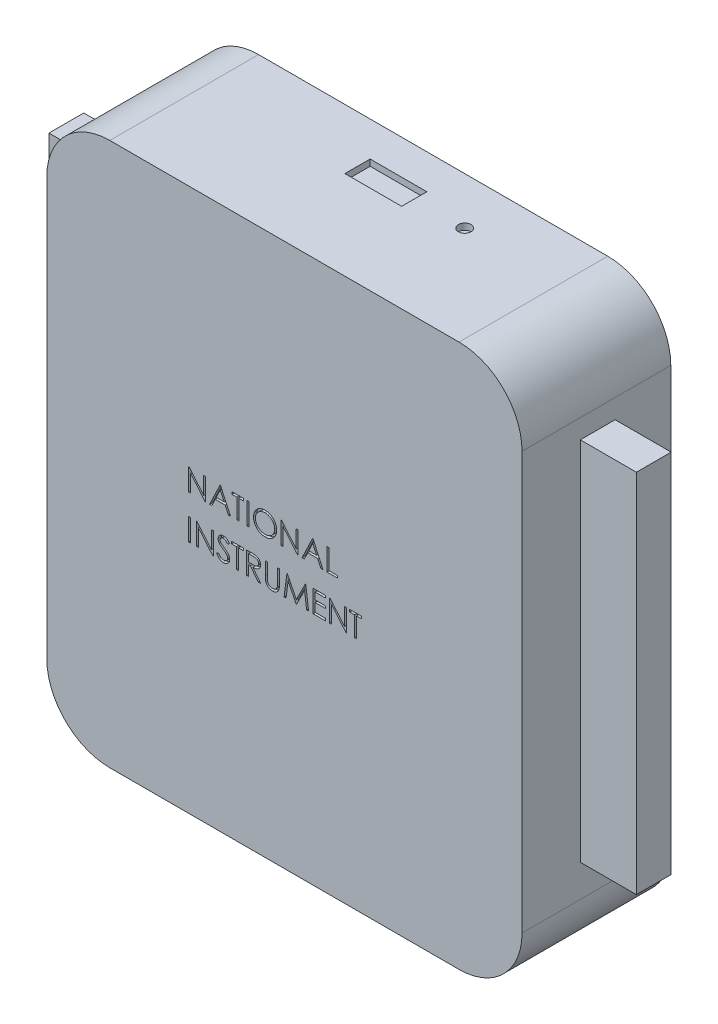
from build123d import *

# Parameters (mm, degrees)
SKETCH1_W                = 75.4
SKETCH1_H                = 86.2
BOSS_EXTRUDE1_DEPTH      = 23.6
SKETCH2_W                = 5.523445924
SKETCH2_H                = 58.042494048
BOSS_EXTRUDE2_DEPTH      = 8.9
BOSS_EXTRUDE2_DEPTH_BACK = 84.3
SKETCH3_W                = 0.314102564
SKETCH3_H                = 3.5
CUT_EXTRUDE1_DEPTH       = 0.5
FILLET1_R                = 10
SKETCH5_R                = 1
SKETCH5_W                = 9
SKETCH5_H                = 4
CUT_EXTRUDE2_DEPTH       = 1


with BuildPart() as part:
    # Sketch1 → Boss-Extrude1 (new body)
    with BuildSketch(Plane.XY):
        with Locations((37.7, 43.1)):
            Rectangle(SKETCH1_W, SKETCH1_H)
    extrude(amount=BOSS_EXTRUDE1_DEPTH)

    # Sketch2 → Boss-Extrude2 (add, two sides)
    with BuildSketch(Plane.ZY) as boss_extrude2_sk:
        with Locations((11.597208394, 44.124044053)):
            Rectangle(SKETCH2_W, SKETCH2_H)
    extrude(amount=BOSS_EXTRUDE2_DEPTH)
    extrude(boss_extrude2_sk.sketch, amount=-BOSS_EXTRUDE2_DEPTH_BACK)

    # Sketch3 → Cut-Extrude1 (cut)
    with BuildSketch(Plane.XY.offset(23.6)):
        Polygon((22.517751212, 44.125723562), (22.517751212, 47.625723562), (22.583656661, 47.625723562), (24.89595634, 44.87101603), (24.89595634, 47.625723562), (25.210058904, 47.625723562), (25.210058904, 44.125723562), (25.138544481, 44.125723562), (22.831853776, 46.874120998), (22.831853776, 44.125723562), align=None)
        Polygon((27.543392238, 47.625723562), (29.158776853, 44.125723562), (28.817330539, 44.125723562), (28.299902654, 45.247518434), (26.713264033, 45.247518434), (26.18111259, 44.125723562), (25.838264033, 44.125723562), (27.498520443, 47.625723562), align=None)
        Polygon((27.517450731, 46.943532055), (26.883636629, 45.606492792), (28.134437911, 45.606492792), align=None, mode=Mode.SUBTRACT)
        Polygon((29.383135827, 47.266749203), (29.383135827, 47.625723562), (31.222879417, 47.625723562), (31.222879417, 47.266749203), (30.460058904, 47.266749203), (30.460058904, 44.125723562), (30.14595634, 44.125723562), (30.14595634, 47.266749203), align=None)
        with Locations((31.918392238, 45.875723562)):
            Rectangle(SKETCH3_W, SKETCH3_H)
        with BuildLine():
            add(Edge.make_bspline(
                [(34.61069993, 47.715467151), (34.675508036, 47.713825672), (34.802796503, 47.710601671), (34.989871401, 47.685922568), (35.168466496, 47.643227178), (35.340036635, 47.586364195), (35.502529611, 47.51050981), (35.657168504, 47.418824661), (35.803585378, 47.310348203), (35.939806759, 47.185918976), (36.064463709, 47.050535522), (36.174289596, 46.906057612), (36.266331889, 46.75335881), (36.341917677, 46.592897979), (36.401216286, 46.425038011), (36.44213533, 46.248884008), (36.46827348, 46.065577318), (36.471329258, 45.940550453), (36.472879417, 45.877125805)],
                knots=[0, 0, 0, 0, 0.000194393, 0.000381804, 0.00056479, 0.000744601, 0.000923091, 0.001101652, 0.001283106, 0.001468738, 0.001654324, 0.001834514, 0.002012231, 0.002188181, 0.002365797, 0.002545211, 0.002729936, 0.002920126, 0.002920126, 0.002920126, 0.002920126], degree=3))
            add(Edge.make_bspline(
                [(36.472879417, 45.877125805), (36.471329485, 45.814168359), (36.468274388, 45.690071939), (36.442105611, 45.507928494), (36.401064611, 45.332837798), (36.342468344, 45.165092145), (36.267242866, 45.004514581), (36.174587695, 44.851527627), (36.065446484, 44.706081129), (35.941239633, 44.569768464), (35.805838591, 44.444770993), (35.660608324, 44.335852117), (35.508815004, 44.242127993), (35.348505296, 44.167344319), (35.181805259, 44.107572398), (35.007222936, 44.066819768), (34.825576382, 44.040532725), (34.701705378, 44.037514209), (34.638744802, 44.035979972)],
                knots=[0, 0, 0, 0, 0.000188789, 0.000372126, 0.000550857, 0.00072758, 0.000904164, 0.001081881, 0.001263191, 0.001448823, 0.00163441, 0.001815159, 0.001992641, 0.002168591, 0.002344885, 0.002522934, 0.002705576, 0.002894365, 0.002894365, 0.002894365, 0.002894365], degree=3))
            add(Edge.make_bspline(
                [(34.638744802, 44.035979972), (34.575320483, 44.037529359), (34.450294267, 44.040583613), (34.266757232, 44.066765018), (34.090479488, 44.107706321), (33.921965136, 44.166215758), (33.761120207, 44.241832988), (33.607630124, 44.334037367), (33.462110977, 44.443444509), (33.32576923, 44.567611083), (33.201020032, 44.702782635), (33.092260657, 44.84761689), (33.000035543, 44.999272347), (32.924672211, 45.158169871), (32.865007751, 45.323541314), (32.824302933, 45.496489791), (32.797966981, 45.676029297), (32.794932135, 45.798272195), (32.793392238, 45.860298882)],
                knots=[0, 0, 0, 0, 0.00019019, 0.000374915, 0.000555011, 0.000732396, 0.00090898, 0.001087298, 0.001268608, 0.00145424, 0.001639827, 0.001819595, 0.001996712, 0.002171394, 0.002346367, 0.002523053, 0.002703612, 0.002889599, 0.002889599, 0.002889599, 0.002889599], degree=3))
            add(Edge.make_bspline(
                [(32.793392238, 45.860298882), (32.793926873, 45.901931551), (32.7949894, 45.984671675), (32.807781092, 46.107538275), (32.826342793, 46.228428933), (32.852944706, 46.346999881), (32.887736373, 46.462960865), (32.9287884, 46.577111628), (32.978928246, 46.688295352), (33.035608894, 46.797038744), (33.098870702, 46.90164665), (33.168746451, 47.000526233), (33.24278182, 47.09450723), (33.323945213, 47.181154233), (33.409561658, 47.26298789), (33.501020036, 47.338750607), (33.597762281, 47.409125558), (33.700204661, 47.472545899), (33.805822935, 47.529905033), (33.914699713, 47.579126884), (34.025356285, 47.621372946), (34.138310933, 47.655613771), (34.253263705, 47.682645807), (34.370465489, 47.701053161), (34.489822916, 47.713877479), (34.570234235, 47.714934981), (34.61069993, 47.715467151)],
                knots=[0, 0, 0, 0, 0.000124849, 0.000248123, 0.000370193, 0.00049164, 0.000612319, 0.000733199, 0.000855287, 0.000977905, 0.001100913, 0.001221706, 0.001340948, 0.001459521, 0.001577551, 0.001696047, 0.001815534, 0.001936153, 0.002057243, 0.002175846, 0.002294342, 0.002412335, 0.002529682, 0.00264829, 0.002768075, 0.00288942, 0.00288942, 0.00288942, 0.00288942], degree=3))
        make_face()
        with BuildLine():
            add(Edge.make_bspline(
                [(34.62612461, 47.356492792), (34.592909976, 47.356087902), (34.526798243, 47.355281993), (34.428513707, 47.344666277), (34.331521773, 47.329536388), (34.235802411, 47.307954867), (34.141756121, 47.278550814), (34.04850628, 47.244709906), (33.956903226, 47.203488816), (33.867249369, 47.156916111), (33.780334293, 47.10536719), (33.698321592, 47.048395423), (33.620998948, 46.987336869), (33.548555681, 46.922049032), (33.481204509, 46.85219943), (33.417619808, 46.778846994), (33.360350226, 46.699895103), (33.307864649, 46.617484696), (33.260896809, 46.531723115), (33.219131454, 46.443513253), (33.184967445, 46.352135566), (33.157105069, 46.258581408), (33.134005258, 46.162998948), (33.119371334, 46.0646631), (33.108638975, 45.964067988), (33.107879129, 45.896086134), (33.107494802, 45.861701126)],
                knots=[0, 0, 0, 0, 9.9599e-05, 0.000198245, 0.000296222, 0.00039402, 0.00049227, 0.000591646, 0.000691452, 0.000793368, 0.000894612, 0.000994383, 0.001092713, 0.00119001, 0.001286696, 0.001383657, 0.001480979, 0.001579008, 0.001676595, 0.001774142, 0.001871547, 0.001968922, 0.002066879, 0.00216624, 0.00226698, 0.002370083, 0.002370083, 0.002370083, 0.002370083], degree=3))
            add(Edge.make_bspline(
                [(33.107494802, 45.861701126), (33.108769664, 45.811138905), (33.111277712, 45.711667375), (33.133235282, 45.565899231), (33.167057256, 45.425810945), (33.216914623, 45.292169035), (33.279265237, 45.163824752), (33.356292128, 45.041916648), (33.447551213, 44.926411773), (33.55121474, 44.818116504), (33.664537446, 44.7192707), (33.784870176, 44.632507291), (33.910923784, 44.559097042), (34.043026986, 44.499291969), (34.180474526, 44.451902231), (34.324152077, 44.4194236), (34.473102536, 44.398048145), (34.574633191, 44.395995389), (34.62612461, 44.394954331)],
                knots=[0, 0, 0, 0, 0.000151605, 0.000298253, 0.000441263, 0.000583229, 0.000725274, 0.000868635, 0.001014928, 0.001166177, 0.001317744, 0.00146543, 0.001610576, 0.001754594, 0.001899821, 0.002045914, 0.002195936, 0.002350312, 0.002350312, 0.002350312, 0.002350312], degree=3))
            add(Edge.make_bspline(
                [(34.62612461, 44.394954331), (34.660734111, 44.395429835), (34.729375148, 44.396372903), (34.83147067, 44.40587158), (34.931726882, 44.42110345), (35.030003161, 44.443034105), (35.126187973, 44.470481312), (35.220682776, 44.50308904), (35.312481066, 44.543770243), (35.402740904, 44.588718195), (35.489137146, 44.639958352), (35.571612678, 44.694996502), (35.648088658, 44.755965123), (35.720477729, 44.820282935), (35.788105418, 44.889246783), (35.850514403, 44.962767005), (35.907494535, 45.041307662), (35.959960181, 45.123593068), (36.006763444, 45.209589321), (36.047542543, 45.298118999), (36.082138659, 45.388964108), (36.110067164, 45.482255679), (36.131952625, 45.577816528), (36.147032545, 45.675774606), (36.157580984, 45.775933949), (36.158376061, 45.843677805), (36.158776853, 45.877826927)],
                knots=[0, 0, 0, 0, 0.000103804, 0.000205874, 0.000307314, 0.000407849, 0.000507719, 0.000607281, 0.000707445, 0.000808723, 0.000909609, 0.001008589, 0.001105934, 0.001202762, 0.001298946, 0.001395452, 0.001491794, 0.001589823, 0.001688026, 0.001785277, 0.001882027, 0.001979402, 0.0020772, 0.002175869, 0.002276609, 0.002379011, 0.002379011, 0.002379011, 0.002379011], degree=3))
            add(Edge.make_bspline(
                [(36.158776853, 45.877826927), (36.15837574, 45.911742431), (36.157580059, 45.979020082), (36.147037584, 46.0784809), (36.131936694, 46.175734111), (36.110173986, 46.270397914), (36.082123832, 46.362496439), (36.047536502, 46.451943187), (36.006751202, 46.539071382), (35.959942978, 46.623665679), (35.907327154, 46.704840417), (35.849832911, 46.78244283), (35.786467563, 46.855015571), (35.719041538, 46.924350265), (35.645870653, 46.988968155), (35.567286358, 47.048890675), (35.484242681, 47.10556395), (35.396315445, 47.156689511), (35.305571492, 47.203903744), (35.212457534, 47.244354747), (35.118028434, 47.278726867), (35.022524322, 47.308043832), (34.925141343, 47.329451862), (34.826537514, 47.344679912), (34.726849256, 47.355278298), (34.659806036, 47.356086676), (34.62612461, 47.356492792)],
                knots=[0, 0, 0, 0, 0.000101701, 0.000201743, 0.00029972, 0.000396835, 0.000492868, 0.000588308, 0.000684288, 0.000781261, 0.000878109, 0.000974304, 0.001070733, 0.001166917, 0.001264269, 0.001363274, 0.001463228, 0.001565678, 0.001668217, 0.001769947, 0.001869982, 0.001969573, 0.002069423, 0.002168785, 0.002268827, 0.002369827, 0.002369827, 0.002369827, 0.002369827], degree=3))
        make_face(mode=Mode.SUBTRACT)
        Polygon((37.190828135, 44.125723562), (37.190828135, 47.625723562), (37.256733584, 47.625723562), (39.569033263, 44.87101603), (39.569033263, 47.625723562), (39.883135827, 47.625723562), (39.883135827, 44.125723562), (39.811621404, 44.125723562), (37.504930699, 46.874120998), (37.504930699, 44.125723562), align=None)
        Polygon((42.216469161, 47.625723562), (43.831853776, 44.125723562), (43.490407462, 44.125723562), (42.972979577, 45.247518434), (41.386340956, 45.247518434), (40.854189513, 44.125723562), (40.511340956, 44.125723562), (42.171597366, 47.625723562), align=None)
        Polygon((42.190527654, 46.943532055), (41.556713552, 45.606492792), (42.807514834, 45.606492792), align=None, mode=Mode.SUBTRACT)
        Polygon((44.460058904, 47.625723562), (44.774161469, 47.625723562), (44.774161469, 44.484697921), (46.120315315, 44.484697921), (46.120315315, 44.125723562), (44.460058904, 44.125723562), align=None)
        with Locations((22.674802494, 39.042390228)):
            Rectangle(SKETCH3_W, SKETCH3_H)
        Polygon((23.729289674, 37.292390228), (23.729289674, 40.792390228), (23.795195122, 40.792390228), (26.107494802, 38.037682696), (26.107494802, 40.792390228), (26.421597366, 40.792390228), (26.421597366, 37.292390228), (26.350082943, 37.292390228), (24.043392238, 40.040787664), (24.043392238, 37.292390228), align=None)
        with BuildLine():
            Line((26.960058904, 37.967570517), (27.255932302, 38.144954331))
            add(Edge.make_bspline(
                [(27.255932302, 38.144954331), (27.283450539, 38.098889946), (27.33617442, 38.010632362), (27.424125779, 37.891374322), (27.51525869, 37.790012165), (27.610248024, 37.707135557), (27.708513972, 37.641886671), (27.810698025, 37.595684439), (27.916455836, 37.566868464), (27.988429658, 37.563368377), (28.024361789, 37.561620998)],
                knots=[0, 0, 0, 0, 0.000160901, 0.00030828, 0.000443778, 0.00056903, 0.000685513, 0.000796284, 0.00090427, 0.001011928, 0.001011928, 0.001011928, 0.001011928], degree=3))
            add(Edge.make_bspline(
                [(28.024361789, 37.561620998), (28.05504865, 37.56247567), (28.115885423, 37.56417006), (28.205447666, 37.580450862), (28.292429468, 37.605462991), (28.375038106, 37.641283923), (28.45213372, 37.684622409), (28.519740415, 37.736968586), (28.578186529, 37.795574792), (28.625995643, 37.860957446), (28.662675678, 37.931274595), (28.690867747, 38.003450546), (28.706512821, 38.078619115), (28.708869574, 38.129229578), (28.710058904, 38.154770036)],
                knots=[0, 0, 0, 0, 9.1978e-05, 0.000182347, 0.000272202, 0.000362975, 0.000451852, 0.000536835, 0.000618639, 0.000699414, 0.000778765, 0.000855983, 0.0009312, 0.001007828, 0.001007828, 0.001007828, 0.001007828], degree=3))
            add(Edge.make_bspline(
                [(28.710058904, 38.154770036), (28.708584594, 38.183910886), (28.705587535, 38.243149975), (28.680256055, 38.330549628), (28.640406809, 38.417042198), (28.603644165, 38.470543463), (28.584558103, 38.498319716)],
                knots=[0, 0, 0, 0, 8.7281e-05, 0.000177429, 0.000270909, 0.000371844, 0.000371844, 0.000371844, 0.000371844], degree=3))
            add(Edge.make_bspline(
                [(28.584558103, 38.498319716), (28.568887489, 38.518366539), (28.535988995, 38.560452338), (28.479431482, 38.623097573), (28.413065368, 38.687715992), (28.339161813, 38.756775049), (28.255028724, 38.827062846), (28.16330121, 38.901931124), (28.061637351, 38.978532701), (27.990337854, 39.029905266), (27.953548488, 39.056412664)],
                knots=[0, 0, 0, 0, 7.6319e-05, 0.000160223, 0.000252933, 0.000354147, 0.000463581, 0.000581729, 0.000709336, 0.000845369, 0.000845369, 0.000845369, 0.000845369], degree=3))
            add(Edge.make_bspline(
                [(27.953548488, 39.056412664), (27.916724492, 39.082641252), (27.846319815, 39.132788314), (27.747861233, 39.207212598), (27.65981677, 39.275256468), (27.582577753, 39.33756048), (27.516178156, 39.394133085), (27.460094745, 39.444431024), (27.415756188, 39.489814585), (27.391100607, 39.519255926), (27.38003086, 39.532474363)],
                knots=[0, 0, 0, 0, 0.000135623, 0.000259301, 0.000370234, 0.000469439, 0.00055697, 0.000631911, 0.000695377, 0.00074709, 0.00074709, 0.00074709, 0.00074709], degree=3))
            add(Edge.make_bspline(
                [(27.38003086, 39.532474363), (27.364558314, 39.5530754), (27.334129478, 39.593590104), (27.293963472, 39.656914961), (27.259824309, 39.721738227), (27.233061977, 39.788234091), (27.210525758, 39.85546902), (27.195367828, 39.924320266), (27.185876431, 39.994478884), (27.184904444, 40.041692385), (27.184417879, 40.065326927)],
                knots=[0, 0, 0, 0, 7.727e-05, 0.000151962, 0.000224716, 0.000296717, 0.00036678, 0.0004372, 0.000507902, 0.000578771, 0.000578771, 0.000578771, 0.000578771], degree=3))
            add(Edge.make_bspline(
                [(27.184417879, 40.065326927), (27.185723088, 40.102356702), (27.188305608, 40.175624765), (27.210146125, 40.282655596), (27.244619019, 40.384842013), (27.292913907, 40.481172347), (27.35517126, 40.569138328), (27.427217234, 40.649751815), (27.51302872, 40.717520397), (27.607181343, 40.776732455), (27.710237715, 40.82307838), (27.818228619, 40.858039361), (27.931325691, 40.877848618), (28.007928826, 40.880691383), (28.046797686, 40.882133818)],
                knots=[0, 0, 0, 0, 0.000110999, 0.000219625, 0.000326272, 0.00043382, 0.000541574, 0.000648775, 0.000756959, 0.000868438, 0.000981703, 0.00109501, 0.001208203, 0.0013248, 0.0013248, 0.0013248, 0.0013248], degree=3))
            add(Edge.make_bspline(
                [(28.046797686, 40.882133818), (28.088041787, 40.880711267), (28.170063138, 40.877882265), (28.290712354, 40.853284734), (28.40687307, 40.812584062), (28.500316335, 40.766395404), (28.573449097, 40.720263989), (28.629221829, 40.678244164), (28.68573928, 40.629869056), (28.743457335, 40.57500981), (28.801397994, 40.513163059), (28.860421447, 40.44475237), (28.920665716, 40.370195814), (28.959421576, 40.316971313), (28.979289674, 40.289685901)],
                knots=[0, 0, 0, 0, 0.000123638, 0.000245877, 0.000367608, 0.000492088, 0.000557638, 0.000626769, 0.000701372, 0.00078072, 0.000865532, 0.000955497, 0.001051745, 0.001152989, 0.001152989, 0.001152989, 0.001152989], degree=3))
            Line((28.979289674, 40.289685901), (28.695335347, 40.07444151))
            add(Edge.make_bspline(
                [(28.695335347, 40.07444151), (28.678189414, 40.096530201), (28.645170357, 40.139067854), (28.59504087, 40.19863917), (28.547792222, 40.253055649), (28.501241823, 40.300320777), (28.457848191, 40.343022911), (28.415731149, 40.379582667), (28.375496798, 40.410358263), (28.324779887, 40.443201823), (28.261062169, 40.475758326), (28.181077632, 40.503307404), (28.097491357, 40.519862466), (28.040561726, 40.522051354), (28.011741597, 40.523159459)],
                knots=[0, 0, 0, 0, 8.3877e-05, 0.000161528, 0.000233552, 0.000299993, 0.000360485, 0.000416152, 0.000467195, 0.000512312, 0.000597287, 0.000681099, 0.000765389, 0.000851809, 0.000851809, 0.000851809, 0.000851809], degree=3))
            add(Edge.make_bspline(
                [(28.011741597, 40.523159459), (27.975585074, 40.521947759), (27.905860627, 40.51961111), (27.806870391, 40.494091125), (27.717776466, 40.453909264), (27.641223901, 40.397594286), (27.577486924, 40.330873294), (27.531381465, 40.254094439), (27.5036313, 40.169312036), (27.500245021, 40.11017038), (27.498520443, 40.080050485)],
                knots=[0, 0, 0, 0, 0.000108248, 0.000208746, 0.00030443, 0.000399793, 0.000492054, 0.00057947, 0.000666386, 0.000756591, 0.000756591, 0.000756591, 0.000756591], degree=3))
            add(Edge.make_bspline(
                [(27.498520443, 40.080050485), (27.49891357, 40.061299006), (27.499700466, 40.023765387), (27.510675263, 39.968313965), (27.524774592, 39.913002625), (27.547117224, 39.858080043), (27.577962528, 39.802585684), (27.618467704, 39.745563946), (27.669481016, 39.686512237), (27.708558028, 39.648104864), (27.729189513, 39.627826927)],
                knots=[0, 0, 0, 0, 5.616e-05, 0.000112411, 0.000169046, 0.000227244, 0.000289691, 0.000359134, 0.000436702, 0.000523463, 0.000523463, 0.000523463, 0.000523463], degree=3))
            add(Edge.make_bspline(
                [(27.729189513, 39.627826927), (27.736850886, 39.620989901), (27.755052553, 39.604746693), (27.788328479, 39.578154412), (27.832271277, 39.54535164), (27.885733478, 39.504764324), (27.94970084, 39.457682861), (28.024180396, 39.404709249), (28.108341929, 39.34412379), (28.168063845, 39.30176625), (28.199642238, 39.279369395)],
                knots=[0, 0, 0, 0, 3.0802e-05, 7.3177e-05, 0.000127725, 0.000195314, 0.000274544, 0.000365991, 0.000469501, 0.000585644, 0.000585644, 0.000585644, 0.000585644], degree=3))
            add(Edge.make_bspline(
                [(28.199642238, 39.279369395), (28.237628151, 39.251728035), (28.311182607, 39.198204374), (28.415840187, 39.117788694), (28.510733995, 39.039140925), (28.596197199, 38.962763318), (28.673074107, 38.889235225), (28.740511828, 38.817672045), (28.799197508, 38.748586472), (28.862376727, 38.660013896), (28.926934546, 38.551232812), (28.982376054, 38.417954574), (29.017334401, 38.284158253), (29.021905917, 38.194231417), (29.024161469, 38.149862184)],
                knots=[0, 0, 0, 0, 0.000140932, 0.000272896, 0.000395881, 0.000510584, 0.000616697, 0.000714904, 0.000805482, 0.000888372, 0.001041088, 0.001183793, 0.001320341, 0.001453327, 0.001453327, 0.001453327, 0.001453327], degree=3))
            add(Edge.make_bspline(
                [(29.024161469, 38.149862184), (29.02350433, 38.118483818), (29.022202815, 38.056336435), (29.007241902, 37.965081358), (28.985322236, 37.876450488), (28.952285002, 37.791539376), (28.911961844, 37.708794613), (28.860795596, 37.630386713), (28.801487912, 37.554580314), (28.733454147, 37.483396823), (28.659008244, 37.418050627), (28.58032455, 37.359921565), (28.497274277, 37.311453242), (28.41030796, 37.2719024), (28.319405623, 37.240968882), (28.22459784, 37.218556013), (28.125728328, 37.204800302), (28.058527847, 37.203372541), (28.024361789, 37.202646639)],
                knots=[0, 0, 0, 0, 9.4044e-05, 0.000186263, 0.000276729, 0.000367488, 0.000459046, 0.000552398, 0.000647774, 0.000747454, 0.000847311, 0.000944634, 0.001040472, 0.001135227, 0.001230788, 0.001328063, 0.00142712, 0.00152957, 0.00152957, 0.00152957, 0.00152957], degree=3))
            add(Edge.make_bspline(
                [(28.024361789, 37.202646639), (27.997926446, 37.20315782), (27.945388686, 37.204173746), (27.867679204, 37.213155026), (27.791539615, 37.22586213), (27.717925333, 37.2460362), (27.645887921, 37.270513177), (27.575740687, 37.300651509), (27.507449633, 37.336768711), (27.44063205, 37.378063735), (27.375457875, 37.42612148), (27.312538407, 37.482094976), (27.249809222, 37.544440481), (27.189121826, 37.614851045), (27.129248681, 37.692189128), (27.071370272, 37.777178311), (27.014288554, 37.869355665), (26.978473086, 37.93422075), (26.960058904, 37.967570517)],
                knots=[0, 0, 0, 0, 7.9276e-05, 0.000157554, 0.000234438, 0.000310629, 0.000386236, 0.000462555, 0.000539392, 0.000617798, 0.000698008, 0.000781971, 0.000870217, 0.00096315, 0.001060616, 0.001163492, 0.001271478, 0.00138575, 0.00138575, 0.00138575, 0.00138575], degree=3))
        make_face()
        Polygon((29.338264033, 40.433415869), (29.338264033, 40.792390228), (31.178007622, 40.792390228), (31.178007622, 40.433415869), (30.41518711, 40.433415869), (30.41518711, 37.292390228), (30.101084545, 37.292390228), (30.101084545, 40.433415869), align=None)
        with BuildLine():
            Line((31.716469161, 40.792390228), (32.416889834, 40.792390228))
            add(Edge.make_bspline(
                [(32.416889834, 40.792390228), (32.463630962, 40.792234642), (32.553379107, 40.7919359), (32.681952377, 40.790270137), (32.798779474, 40.785495781), (32.903799313, 40.781387198), (32.997009968, 40.773895257), (33.078697259, 40.76673461), (33.148484957, 40.757360949), (33.190730808, 40.748655526), (33.209858584, 40.744713946)],
                knots=[0, 0, 0, 0, 0.000140226, 0.00026925, 0.000385712, 0.000490995, 0.000584507, 0.000666202, 0.000736998, 0.000795574, 0.000795574, 0.000795574, 0.000795574], degree=3))
            add(Edge.make_bspline(
                [(33.209858584, 40.744713946), (33.235465208, 40.738387181), (33.286132197, 40.725868617), (33.359082264, 40.699409016), (33.428596587, 40.668789392), (33.494386412, 40.632825672), (33.556122203, 40.591250892), (33.614440514, 40.544782769), (33.669605977, 40.493675564), (33.719387607, 40.436640722), (33.766326659, 40.376804212), (33.805915286, 40.312100456), (33.840041765, 40.244438928), (33.867212282, 40.17313151), (33.889090256, 40.098869739), (33.904516495, 40.020980942), (33.913767683, 39.939819967), (33.914709538, 39.884462058), (33.91518711, 39.856392632)],
                knots=[0, 0, 0, 0, 7.9081e-05, 0.000156475, 0.000232432, 0.000306798, 0.00038108, 0.000455429, 0.000530331, 0.000606314, 0.000682321, 0.000758201, 0.000833453, 0.000909362, 0.000986794, 0.001065445, 0.001147284, 0.001231465, 0.001231465, 0.001231465, 0.001231465], degree=3))
            add(Edge.make_bspline(
                [(33.91518711, 39.856392632), (33.913718111, 39.809757528), (33.910851716, 39.71876036), (33.884126612, 39.586699478), (33.840350092, 39.463510164), (33.780026803, 39.349347526), (33.703207328, 39.24643688), (33.610882536, 39.156046425), (33.503000925, 39.080406513), (33.402571609, 39.027953708), (33.313857409, 38.994360799), (33.240824096, 38.97072444), (33.161157119, 38.952462475), (33.075619784, 38.936102343), (32.983856129, 38.923750649), (32.88608609, 38.914704054), (32.782239938, 38.909050006), (32.710900869, 38.908208001), (32.674201533, 38.907774844)],
                knots=[0, 0, 0, 0, 0.000139777, 0.000272741, 0.000402249, 0.000530843, 0.000658588, 0.000786009, 0.000916741, 0.001052522, 0.001124656, 0.001201155, 0.001282612, 0.001369656, 0.001462366, 0.001560247, 0.001664165, 0.001774261, 0.001774261, 0.001774261, 0.001774261], degree=3))
            Line((32.674201533, 38.907774844), (33.960058904, 37.292390228))
            Line((33.960058904, 37.292390228), (33.57163743, 37.292390228))
            Line((33.57163743, 37.292390228), (32.285780058, 38.907774844))
            Line((32.285780058, 38.907774844), (32.030571725, 38.907774844))
            Line((32.030571725, 38.907774844), (32.030571725, 37.292390228))
            Line((32.030571725, 37.292390228), (31.716469161, 37.292390228))
            Line((31.716469161, 37.292390228), (31.716469161, 40.792390228))
        make_face()
        with BuildLine():
            Line((32.030571725, 40.433415869), (32.030571725, 39.266749203))
            Line((32.030571725, 39.266749203), (32.671397045, 39.26184135))
            add(Edge.make_bspline(
                [(32.671397045, 39.26184135), (32.701317084, 39.261828114), (32.759310641, 39.261802457), (32.843211306, 39.265796233), (32.921331418, 39.270339552), (32.99337217, 39.277288897), (33.059365745, 39.286244969), (33.119279159, 39.297447953), (33.173210211, 39.310500016), (33.236108749, 39.330701642), (33.30634528, 39.36270766), (33.38267674, 39.409273159), (33.447679078, 39.467842278), (33.50259694, 39.534815734), (33.546726372, 39.608451983), (33.577838426, 39.687868352), (33.597580868, 39.77105995), (33.599909414, 39.828238058), (33.601084545, 39.857093754)],
                knots=[0, 0, 0, 0, 8.9746e-05, 0.000173954, 0.000251933, 0.000324488, 0.000391021, 0.000451663, 0.000507268, 0.000557378, 0.000649639, 0.000738152, 0.000824558, 0.000910739, 0.000997194, 0.001080909, 0.00116578, 0.001252248, 0.001252248, 0.001252248, 0.001252248], degree=3))
            add(Edge.make_bspline(
                [(33.601084545, 39.857093754), (33.599882424, 39.885240328), (33.597500259, 39.941016566), (33.57805149, 40.022672477), (33.545162109, 40.099739427), (33.500839871, 40.171903912), (33.446840716, 40.237409648), (33.383522904, 40.293456801), (33.312617708, 40.339706265), (33.24634651, 40.369260646), (33.187112298, 40.387380499), (33.135682637, 40.400131663), (33.07757116, 40.410376132), (33.012495701, 40.418584193), (32.94073407, 40.425639137), (32.861923419, 40.430390916), (32.776586639, 40.43320478), (32.717439708, 40.433343869), (32.686821725, 40.433415869)],
                knots=[0, 0, 0, 0, 8.4371e-05, 0.000167192, 0.000250141, 0.000334794, 0.000420435, 0.000503871, 0.000587493, 0.000673488, 0.0007205, 0.000773215, 0.000832351, 0.0008974, 0.000969955, 0.001048634, 0.001134217, 0.001226067, 0.001226067, 0.001226067, 0.001226067], degree=3))
            Line((32.686821725, 40.433415869), (32.030571725, 40.433415869))
        make_face(mode=Mode.SUBTRACT)
        with BuildLine():
            Line((34.678007622, 40.792390228), (34.992110186, 40.792390228))
            Line((34.992110186, 40.792390228), (34.992110186, 38.69533494))
            add(Edge.make_bspline(
                [(34.992110186, 38.69533494), (34.992063442, 38.665654204), (34.991974738, 38.609329893), (34.992567252, 38.529161593), (34.99422662, 38.457889134), (34.99527278, 38.395237786), (34.997600113, 38.341495039), (34.99949816, 38.296369728), (35.001938717, 38.260075525), (35.004871834, 38.238894599), (35.006132622, 38.229790068)],
                knots=[0, 0, 0, 0, 8.9042e-05, 0.000168973, 0.000240502, 0.000302917, 0.000356945, 0.000401866, 0.000438432, 0.000465999, 0.000465999, 0.000465999, 0.000465999], degree=3))
            add(Edge.make_bspline(
                [(35.006132622, 38.229790068), (35.011310081, 38.196943305), (35.021373267, 38.133100576), (35.047019645, 38.042192294), (35.082837146, 37.960260836), (35.125280189, 37.884749544), (35.1812128, 37.817760184), (35.248216336, 37.756048532), (35.329394104, 37.702076727), (35.41965471, 37.652725915), (35.516939947, 37.613060833), (35.616351214, 37.583067468), (35.716394193, 37.564788569), (35.783370358, 37.56267203), (35.816629417, 37.561620998)],
                knots=[0, 0, 0, 0, 9.971e-05, 0.000193801, 0.000282365, 0.000367504, 0.000452699, 0.000543015, 0.000639862, 0.000744331, 0.000851226, 0.000954377, 0.001055468, 0.001155185, 0.001155185, 0.001155185, 0.001155185], degree=3))
            add(Edge.make_bspline(
                [(35.816629417, 37.561620998), (35.845183158, 37.562694848), (35.90212572, 37.564836346), (35.98673215, 37.578097777), (36.069132259, 37.601998343), (36.149732939, 37.632838101), (36.225283923, 37.673585692), (36.295827365, 37.720656532), (36.358791299, 37.775867408), (36.416249297, 37.836967752), (36.466284233, 37.905907552), (36.509655375, 37.98118569), (36.545181304, 38.063935037), (36.562724829, 38.12208946), (36.57173759, 38.151965549)],
                knots=[0, 0, 0, 0, 8.5678e-05, 0.00017086, 0.000256092, 0.000342674, 0.000429242, 0.000513055, 0.000596556, 0.000679898, 0.000764179, 0.00085149, 0.000940054, 0.001033621, 0.001033621, 0.001033621, 0.001033621], degree=3))
            add(Edge.make_bspline(
                [(36.57173759, 38.151965549), (36.574737716, 38.164314123), (36.581423204, 38.191831723), (36.587670249, 38.238353014), (36.594176774, 38.293242378), (36.598691344, 38.356894191), (36.603092565, 38.429095163), (36.605725637, 38.510221421), (36.60694267, 38.599978382), (36.607305351, 38.662615543), (36.607494802, 38.69533494)],
                knots=[0, 0, 0, 0, 3.81e-05, 8.4902e-05, 0.000140649, 0.000203941, 0.000276279, 0.000357657, 0.000447412, 0.000545571, 0.000545571, 0.000545571, 0.000545571], degree=3))
            Line((36.607494802, 38.69533494), (36.607494802, 40.792390228))
            Line((36.607494802, 40.792390228), (36.921597366, 40.792390228))
            Line((36.921597366, 40.792390228), (36.921597366, 38.678508017))
            add(Edge.make_bspline(
                [(36.921597366, 38.678508017), (36.921343246, 38.640409638), (36.920847314, 38.566058335), (36.916546738, 38.457106976), (36.909689738, 38.353753995), (36.90000165, 38.255985498), (36.887164647, 38.164151339), (36.872889426, 38.077446571), (36.854709893, 37.996493578), (36.833476492, 37.92066116), (36.809202944, 37.848475647), (36.777761796, 37.779967032), (36.742337296, 37.713052633), (36.700322643, 37.648744524), (36.65311126, 37.586757971), (36.599659579, 37.527468896), (36.541735418, 37.469929849), (36.478375859, 37.415616783), (36.410625334, 37.365808106), (36.338685376, 37.322010335), (36.263108606, 37.284986718), (36.18409148, 37.254510793), (36.101600277, 37.231596194), (36.015632917, 37.214521038), (35.925993724, 37.204818741), (35.865029068, 37.203376811), (35.834157462, 37.202646639)],
                knots=[0, 0, 0, 0, 0.000114291, 0.000223047, 0.000327049, 0.000424998, 0.000517708, 0.000605194, 0.000688542, 0.000766455, 0.0008414, 0.000916717, 0.000992315, 0.001068354, 0.001146882, 0.001225836, 0.001307639, 0.001391671, 0.001475952, 0.001559641, 0.001643989, 0.001728103, 0.001813335, 0.001900511, 0.00199079, 0.002083404, 0.002083404, 0.002083404, 0.002083404], degree=3))
            add(Edge.make_bspline(
                [(35.834157462, 37.202646639), (35.800488359, 37.203431404), (35.734429701, 37.204971111), (35.637091633, 37.213793861), (35.543777437, 37.230412255), (35.45350156, 37.251572199), (35.367493063, 37.280755936), (35.284599618, 37.314854061), (35.206240937, 37.356731321), (35.131145809, 37.403324714), (35.061321053, 37.455749352), (34.997223649, 37.512889526), (34.938747779, 37.573829904), (34.886879083, 37.639230269), (34.840758198, 37.708581976), (34.801027985, 37.782081216), (34.76691474, 37.859699532), (34.749308173, 37.913652733), (34.740407462, 37.940927889)],
                knots=[0, 0, 0, 0, 0.000101022, 0.000198206, 0.000292839, 0.000385177, 0.00047608, 0.000565014, 0.000653769, 0.000742283, 0.000829923, 0.000915339, 0.000999643, 0.001082971, 0.00116542, 0.001249186, 0.001333332, 0.001419362, 0.001419362, 0.001419362, 0.001419362], degree=3))
            add(Edge.make_bspline(
                [(34.740407462, 37.940927889), (34.735230304, 37.959560463), (34.724000933, 37.999974932), (34.711975635, 38.066861421), (34.701866553, 38.143876338), (34.692360995, 38.231024957), (34.686752037, 38.328374823), (34.681834598, 38.435883739), (34.67797298, 38.553681701), (34.677995752, 38.635736216), (34.678007622, 38.678508017)],
                knots=[0, 0, 0, 0, 5.799e-05, 0.000125782, 0.000203619, 0.000291034, 0.000388694, 0.000496078, 0.000613919, 0.000742226, 0.000742226, 0.000742226, 0.000742226], degree=3))
            Line((34.678007622, 38.678508017), (34.678007622, 40.792390228))
        make_face()
        Polygon((37.639546084, 37.292390228), (38.101585347, 40.792390228), (38.146457142, 40.792390228), (39.591469161, 37.920595357), (41.032975571, 40.792390228), (41.078548488, 40.792390228), (41.543392238, 37.292390228), (41.22788743, 37.292390228), (40.892751212, 39.810819716), (39.629329738, 37.292390228), (39.558516436, 37.292390228), (38.29018711, 39.81642869), (37.955752013, 37.292390228), align=None)
        Polygon((42.261340956, 40.792390228), (44.23569993, 40.792390228), (44.23569993, 40.433415869), (42.57544352, 40.433415869), (42.57544352, 39.356492792), (44.23569993, 39.356492792), (44.23569993, 38.997518434), (42.57544352, 38.997518434), (42.57544352, 37.651364587), (44.23569993, 37.651364587), (44.23569993, 37.292390228), (42.261340956, 37.292390228), align=None)
        Polygon((44.863905058, 37.292390228), (44.863905058, 40.792390228), (44.929810507, 40.792390228), (47.242110186, 38.037682696), (47.242110186, 40.792390228), (47.556212751, 40.792390228), (47.556212751, 37.292390228), (47.484698327, 37.292390228), (45.178007622, 40.040787664), (45.178007622, 37.292390228), align=None)
        Polygon((48.049802494, 40.433415869), (48.049802494, 40.792390228), (49.889546084, 40.792390228), (49.889546084, 40.433415869), (49.126725571, 40.433415869), (49.126725571, 37.292390228), (48.812623007, 37.292390228), (48.812623007, 40.433415869), align=None)
    extrude(amount=-CUT_EXTRUDE1_DEPTH, mode=Mode.SUBTRACT)

    # Fillet1
    fillet1_edges = [part.edges().sort_by_distance(p)[0] for p in [
        (0, 0, 11.8),
        (75.4, 0, 11.8),
        (0, 86.2, 11.8),
        (75.4, 86.2, 11.8),
    ]]
    fillet(fillet1_edges, radius=FILLET1_R)

    # Sketch5 → Cut-Extrude2 (cut)
    with BuildSketch(Plane(origin=(0, 86.2, 0), x_dir=(1, 0, 0), z_dir=(0, 1, 0))):
        with Locations((50.2, -7.5)):
            Circle(SKETCH5_R)
        with Locations((37.7, -7.5)):
            Rectangle(SKETCH5_W, SKETCH5_H)
    extrude(amount=-CUT_EXTRUDE2_DEPTH, mode=Mode.SUBTRACT)


solid = part.part
